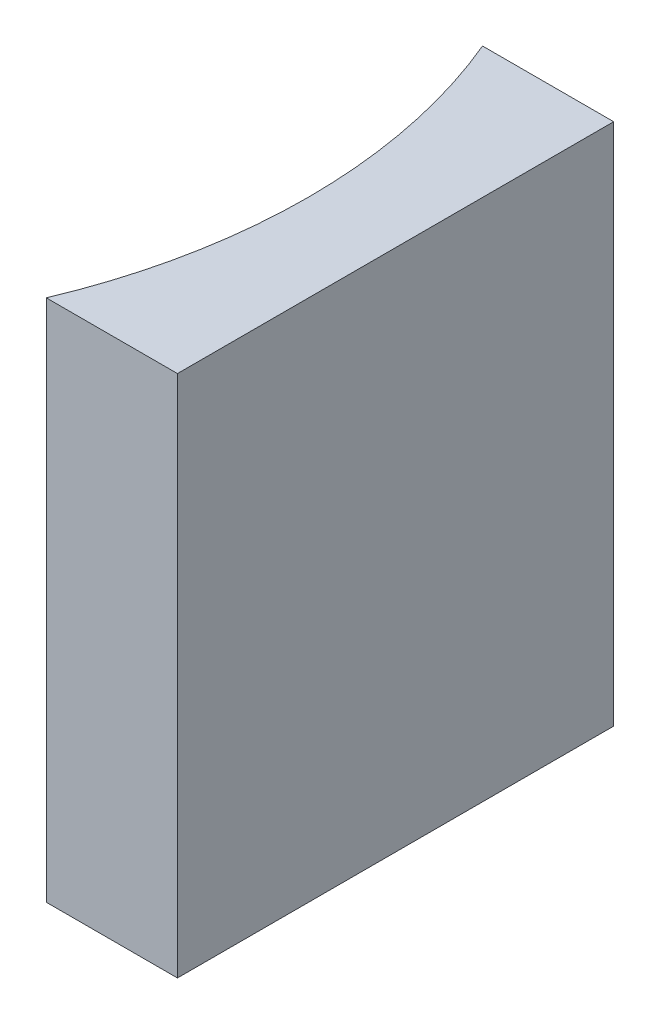
from build123d import *

# Parameters (mm, degrees)
EXTRUDE_1_DEPTH = 12


with BuildPart() as part:
    # 草图1 → 凸台-拉伸1 (new body)
    with BuildSketch(Plane(origin=(0, 0, 0), x_dir=(1, 0, 0), z_dir=(0, 1, 0))):
        with BuildLine():
            Line((0, 0), (0, -10))
            Line((0, -10), (-3.005869004, -10))
            ThreePointArc((-3.005869004, -10), (-2, -5), (-3.005869004, 0))
            Line((-3.005869004, 0), (0, 0))
        make_face()
    extrude(amount=EXTRUDE_1_DEPTH)


solid = part.part
